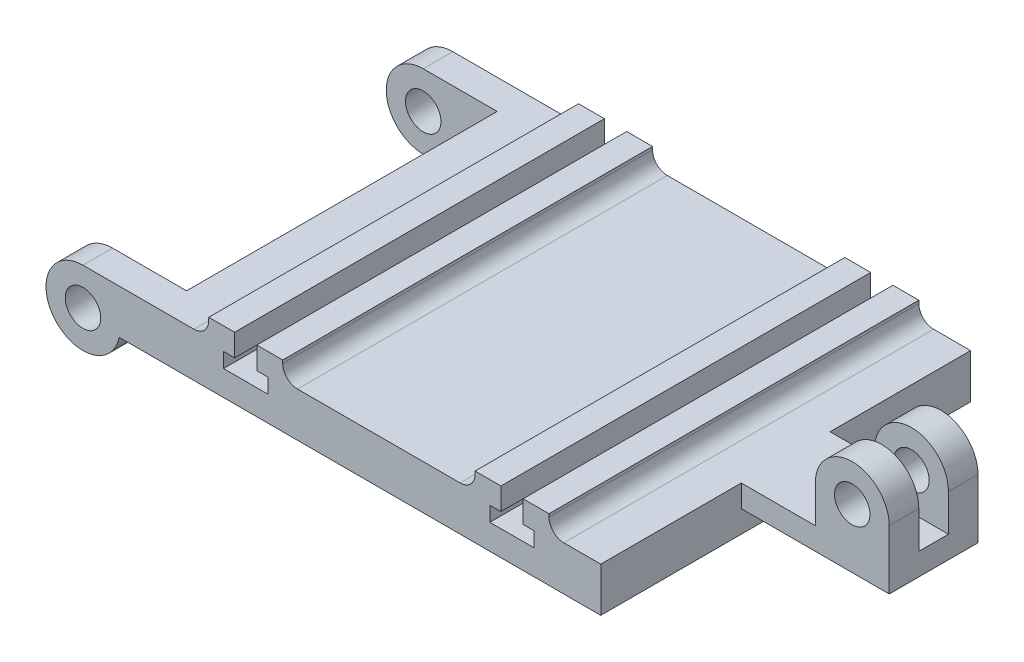
from build123d import *

# Parameters (mm, degrees)
ESBO_O1_W                         = 300
ESBO_O1_H                         = 250
RESSALTO_EXTRUS_O1_DEPTH          = 30
ESBO_O3_W                         = 50
ESBO_O3_H                         = 250
RESSALTO_EXTRUS_O2_DEPTH          = 12
FILETE1_R                         = 10
CORTE_EXTRUS_O1_REACH             = 127
CORTE_EXTRUS_O1_DIRECTION_2_REACH = 127
ESBO_O5_R                         = 12
RESSALTO_EXTRUS_O3_DEPTH          = 30
ESBO_O6_W                         = 60.214883571
ESBO_O6_H                         = 66.59752961
CORTE_EXTRUS_O2_DEPTH             = 10
ESBO_O7_R                         = 12
RESSALTO_EXTRUS_O4_DEPTH          = 20
ESBO_O8_W                         = 260
ESBO_O8_H                         = 210
CORTE_EXTRUS_O3_DEPTH             = 10


with BuildPart() as part:
    # Esboço1 → Ressalto-extrusão1 (new body)
    with BuildSketch(Plane(origin=(0, 0, 0), x_dir=(1, 0, 0), z_dir=(0, 1, 0))):
        Rectangle(ESBO_O1_W, ESBO_O1_H)
    extrude(amount=RESSALTO_EXTRUS_O1_DEPTH)

    # Esboço3 → Ressalto-extrusão2 (add)
    with BuildSketch(Plane(origin=(0, 30, 0), x_dir=(1, 0, 0), z_dir=(0, 1, 0))):
        with Locations((90, 0)):
            Rectangle(ESBO_O3_W, ESBO_O3_H)
        with Locations((-90, 0)):
            Rectangle(ESBO_O3_W, ESBO_O3_H)
    extrude(amount=RESSALTO_EXTRUS_O2_DEPTH)

    # Filete1
    filete1_edges = [part.edges().sort_by_distance(p)[0] for p in [
        (-115, 30, 0),
        (-65, 30, 0),
        (65, 30, 0),
        (115, 30, 0),
    ]]
    fillet(filete1_edges, radius=FILETE1_R)

    # Esboço4 → Corte-extrusão1 (cut, up to next)
    with BuildSketch(Plane.XY, mode=Mode.PRIVATE) as corte_extrus_o1_sk1:
        Polygon((82.5, 42), (97.5, 42), (97.5, 27), (105, 27), (105, 17), (75, 17), (75, 27), (82.5, 27), align=None)
    corte_extrus_o1_tool1 = extrude(corte_extrus_o1_sk1.sketch, amount=-CORTE_EXTRUS_O1_REACH, mode=Mode.PRIVATE) & part.part
    add(corte_extrus_o1_tool1.solids().sort_by_distance((90, 27.357143, 0))[0], mode=Mode.SUBTRACT)
    # Esboço4 → Corte-extrusão1 (cut, up to next)
    with BuildSketch(Plane.XY, mode=Mode.PRIVATE) as corte_extrus_o1_sk2:
        Polygon((-82.5, 42), (-82.5, 27), (-75, 27), (-75, 17), (-105, 17), (-105, 27), (-97.5, 27), (-97.5, 42), align=None)
    corte_extrus_o1_tool2 = extrude(corte_extrus_o1_sk2.sketch, amount=-CORTE_EXTRUS_O1_REACH, mode=Mode.PRIVATE) & part.part
    add(corte_extrus_o1_tool2.solids().sort_by_distance((-90, 27.357143, 0))[0], mode=Mode.SUBTRACT)

    # Esboço4 → Corte-extrusão1 direction 2 (cut, up to next)
    with BuildSketch(Plane.XY, mode=Mode.PRIVATE) as corte_extrus_o1_direction_2_sk1:
        Polygon((82.5, 42), (97.5, 42), (97.5, 27), (105, 27), (105, 17), (75, 17), (75, 27), (82.5, 27), align=None)
    corte_extrus_o1_direction_2_tool1 = extrude(corte_extrus_o1_direction_2_sk1.sketch, amount=CORTE_EXTRUS_O1_DIRECTION_2_REACH, mode=Mode.PRIVATE) & part.part
    add(corte_extrus_o1_direction_2_tool1.solids().sort_by_distance((90, 27.357143, 0))[0], mode=Mode.SUBTRACT)
    # Esboço4 → Corte-extrusão1 direction 2 (cut, up to next)
    with BuildSketch(Plane.XY, mode=Mode.PRIVATE) as corte_extrus_o1_direction_2_sk2:
        Polygon((-82.5, 42), (-82.5, 27), (-75, 27), (-75, 17), (-105, 17), (-105, 27), (-97.5, 27), (-97.5, 42), align=None)
    corte_extrus_o1_direction_2_tool2 = extrude(corte_extrus_o1_direction_2_sk2.sketch, amount=CORTE_EXTRUS_O1_DIRECTION_2_REACH, mode=Mode.PRIVATE) & part.part
    add(corte_extrus_o1_direction_2_tool2.solids().sort_by_distance((-90, 27.357143, 0))[0], mode=Mode.SUBTRACT)

    # Esboço5 → Ressalto-extrusão3 (add, symmetric)
    with BuildSketch(Plane.XY):
        with BuildLine():
            Line((150, 30), (200, 30))
            Line((200, 30), (200, 55))
            ThreePointArc((200, 55), (225, 80), (250, 55))
            Line((250, 55), (250, 15))
            Line((250, 15), (150, 15))
            Line((150, 15), (150, 30))
        make_face()
        with Locations((225, 55)):
            Circle(ESBO_O5_R, mode=Mode.SUBTRACT)
    extrude(amount=RESSALTO_EXTRUS_O3_DEPTH, both=True)

    # Esboço6 → Corte-extrusão2 (cut, symmetric)
    with BuildSketch(Plane.XY):
        with Locations((230.107441786, 63.298764805)):
            Rectangle(ESBO_O6_W, ESBO_O6_H)
    extrude(amount=CORTE_EXTRUS_O2_DEPTH, both=True, mode=Mode.SUBTRACT)

    # Esboço7 → Ressalto-extrusão4 (add)
    with BuildSketch(Plane.XY.offset(125)):
        with BuildLine():
            Line((-150, 30), (-200, 30))
            ThreePointArc((-200, 30), (-219.364916731, -10.811388301), (-175.505102572, 0))
            Line((-175.505102572, 0), (-150, 0))
            Line((-150, 0), (-150, 30))
        make_face()
        with Locations((-200, 5)):
            Circle(ESBO_O7_R, mode=Mode.SUBTRACT)
    ressalto_extrus_o4 = extrude(amount=-RESSALTO_EXTRUS_O4_DEPTH)

    # Espelhar1: Ressalto-extrusão4 across plane
    add(ressalto_extrus_o4.mirror(Plane.XY))

    # Esboço8 → Corte-extrusão3 (cut)
    with BuildSketch(Plane.XZ):
        Rectangle(ESBO_O8_W, ESBO_O8_H)
    extrude(amount=-CORTE_EXTRUS_O3_DEPTH, mode=Mode.SUBTRACT)


solid = part.part
